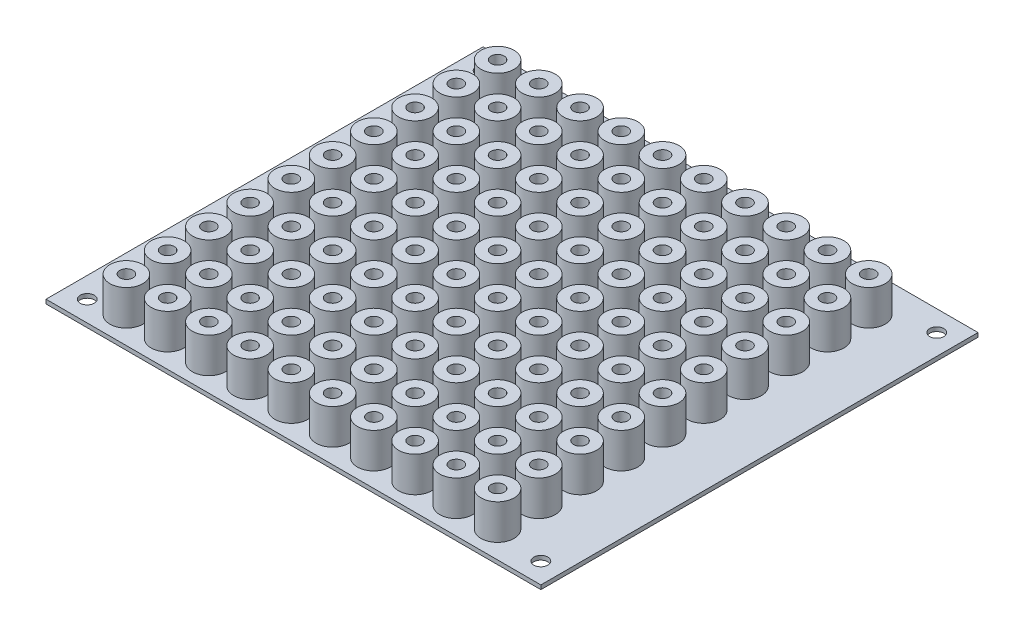
from build123d import *

# Parameters (mm, degrees)
SKETCH1_W           = 120
SKETCH1_H           = 106
SKETCH1_R           = 1.25
SKETCH1_R_2         = 1.7
BOSS_EXTRUDE1_DEPTH = 1
SKETCH2_R           = 4
SKETCH2_R_2         = 1.6
BOSS_EXTRUDE2_DEPTH = 8.525


with BuildPart() as part:
    # Sketch1 → Boss-Extrude1 (new body)
    with BuildSketch(Plane(origin=(0, 0, 0), x_dir=(1, 0, 0), z_dir=(0, 1, 0))):
        with Locations((60, 53)):
            Rectangle(SKETCH1_W, SKETCH1_H)
        with Locations((13, 66.5)):
            Circle(SKETCH1_R, mode=Mode.SUBTRACT)
        with Locations((23, 66.5)):
            Circle(SKETCH1_R, mode=Mode.SUBTRACT)
        with Locations((13, 96.5)):
            Circle(SKETCH1_R, mode=Mode.SUBTRACT)
        with Locations((5, 5)):
            Circle(SKETCH1_R_2, mode=Mode.SUBTRACT)
        with Locations((5, 101)):
            Circle(SKETCH1_R_2, mode=Mode.SUBTRACT)
        with Locations((115, 101)):
            Circle(SKETCH1_R_2, mode=Mode.SUBTRACT)
        with Locations((115, 5)):
            Circle(SKETCH1_R_2, mode=Mode.SUBTRACT)
        with Locations((23, 96.5)):
            Circle(SKETCH1_R, mode=Mode.SUBTRACT)
        with Locations((33, 96.5)):
            Circle(SKETCH1_R, mode=Mode.SUBTRACT)
        with Locations((23, 86.5)):
            Circle(SKETCH1_R, mode=Mode.SUBTRACT)
        with Locations((33, 86.5)):
            Circle(SKETCH1_R, mode=Mode.SUBTRACT)
        with Locations((23, 76.5)):
            Circle(SKETCH1_R, mode=Mode.SUBTRACT)
        with Locations((33, 76.5)):
            Circle(SKETCH1_R, mode=Mode.SUBTRACT)
        with Locations((13, 86.5)):
            Circle(SKETCH1_R, mode=Mode.SUBTRACT)
        with Locations((13, 76.5)):
            Circle(SKETCH1_R, mode=Mode.SUBTRACT)
        with Locations((33, 66.5)):
            Circle(SKETCH1_R, mode=Mode.SUBTRACT)
        with Locations((13, 56.5)):
            Circle(SKETCH1_R, mode=Mode.SUBTRACT)
        with Locations((23, 56.5)):
            Circle(SKETCH1_R, mode=Mode.SUBTRACT)
        with Locations((33, 56.5)):
            Circle(SKETCH1_R, mode=Mode.SUBTRACT)
        with Locations((13, 46.5)):
            Circle(SKETCH1_R, mode=Mode.SUBTRACT)
        with Locations((23, 46.5)):
            Circle(SKETCH1_R, mode=Mode.SUBTRACT)
        with Locations((33, 46.5)):
            Circle(SKETCH1_R, mode=Mode.SUBTRACT)
        with Locations((13, 36.5)):
            Circle(SKETCH1_R, mode=Mode.SUBTRACT)
        with Locations((23, 36.5)):
            Circle(SKETCH1_R, mode=Mode.SUBTRACT)
        with Locations((33, 36.5)):
            Circle(SKETCH1_R, mode=Mode.SUBTRACT)
        with Locations((13, 26.5)):
            Circle(SKETCH1_R, mode=Mode.SUBTRACT)
        with Locations((23, 26.5)):
            Circle(SKETCH1_R, mode=Mode.SUBTRACT)
        with Locations((33, 26.5)):
            Circle(SKETCH1_R, mode=Mode.SUBTRACT)
        with Locations((13, 16.5)):
            Circle(SKETCH1_R, mode=Mode.SUBTRACT)
        with Locations((23, 16.5)):
            Circle(SKETCH1_R, mode=Mode.SUBTRACT)
        with Locations((33, 16.5)):
            Circle(SKETCH1_R, mode=Mode.SUBTRACT)
        with Locations((13, 6.5)):
            Circle(SKETCH1_R, mode=Mode.SUBTRACT)
        with Locations((23, 6.5)):
            Circle(SKETCH1_R, mode=Mode.SUBTRACT)
        with Locations((33, 6.5)):
            Circle(SKETCH1_R, mode=Mode.SUBTRACT)
        with Locations((43, 96.5)):
            Circle(SKETCH1_R, mode=Mode.SUBTRACT)
        with Locations((53, 96.5)):
            Circle(SKETCH1_R, mode=Mode.SUBTRACT)
        with Locations((63, 96.5)):
            Circle(SKETCH1_R, mode=Mode.SUBTRACT)
        with Locations((73, 96.5)):
            Circle(SKETCH1_R, mode=Mode.SUBTRACT)
        with Locations((83, 96.5)):
            Circle(SKETCH1_R, mode=Mode.SUBTRACT)
        with Locations((93, 96.5)):
            Circle(SKETCH1_R, mode=Mode.SUBTRACT)
        with Locations((103, 96.5)):
            Circle(SKETCH1_R, mode=Mode.SUBTRACT)
        with Locations((43, 86.5)):
            Circle(SKETCH1_R, mode=Mode.SUBTRACT)
        with Locations((53, 86.5)):
            Circle(SKETCH1_R, mode=Mode.SUBTRACT)
        with Locations((63, 86.5)):
            Circle(SKETCH1_R, mode=Mode.SUBTRACT)
        with Locations((73, 86.5)):
            Circle(SKETCH1_R, mode=Mode.SUBTRACT)
        with Locations((83, 86.5)):
            Circle(SKETCH1_R, mode=Mode.SUBTRACT)
        with Locations((93, 86.5)):
            Circle(SKETCH1_R, mode=Mode.SUBTRACT)
        with Locations((103, 86.5)):
            Circle(SKETCH1_R, mode=Mode.SUBTRACT)
        with Locations((43, 76.5)):
            Circle(SKETCH1_R, mode=Mode.SUBTRACT)
        with Locations((53, 76.5)):
            Circle(SKETCH1_R, mode=Mode.SUBTRACT)
        with Locations((63, 76.5)):
            Circle(SKETCH1_R, mode=Mode.SUBTRACT)
        with Locations((73, 76.5)):
            Circle(SKETCH1_R, mode=Mode.SUBTRACT)
        with Locations((83, 76.5)):
            Circle(SKETCH1_R, mode=Mode.SUBTRACT)
        with Locations((93, 76.5)):
            Circle(SKETCH1_R, mode=Mode.SUBTRACT)
        with Locations((103, 76.5)):
            Circle(SKETCH1_R, mode=Mode.SUBTRACT)
        with Locations((43, 66.5)):
            Circle(SKETCH1_R, mode=Mode.SUBTRACT)
        with Locations((53, 66.5)):
            Circle(SKETCH1_R, mode=Mode.SUBTRACT)
        with Locations((63, 66.5)):
            Circle(SKETCH1_R, mode=Mode.SUBTRACT)
        with Locations((73, 66.5)):
            Circle(SKETCH1_R, mode=Mode.SUBTRACT)
        with Locations((83, 66.5)):
            Circle(SKETCH1_R, mode=Mode.SUBTRACT)
        with Locations((93, 66.5)):
            Circle(SKETCH1_R, mode=Mode.SUBTRACT)
        with Locations((103, 66.5)):
            Circle(SKETCH1_R, mode=Mode.SUBTRACT)
        with Locations((43, 56.5)):
            Circle(SKETCH1_R, mode=Mode.SUBTRACT)
        with Locations((53, 56.5)):
            Circle(SKETCH1_R, mode=Mode.SUBTRACT)
        with Locations((63, 56.5)):
            Circle(SKETCH1_R, mode=Mode.SUBTRACT)
        with Locations((73, 56.5)):
            Circle(SKETCH1_R, mode=Mode.SUBTRACT)
        with Locations((83, 56.5)):
            Circle(SKETCH1_R, mode=Mode.SUBTRACT)
        with Locations((93, 56.5)):
            Circle(SKETCH1_R, mode=Mode.SUBTRACT)
        with Locations((103, 56.5)):
            Circle(SKETCH1_R, mode=Mode.SUBTRACT)
        with Locations((43, 46.5)):
            Circle(SKETCH1_R, mode=Mode.SUBTRACT)
        with Locations((53, 46.5)):
            Circle(SKETCH1_R, mode=Mode.SUBTRACT)
        with Locations((63, 46.5)):
            Circle(SKETCH1_R, mode=Mode.SUBTRACT)
        with Locations((73, 46.5)):
            Circle(SKETCH1_R, mode=Mode.SUBTRACT)
        with Locations((83, 46.5)):
            Circle(SKETCH1_R, mode=Mode.SUBTRACT)
        with Locations((93, 46.5)):
            Circle(SKETCH1_R, mode=Mode.SUBTRACT)
        with Locations((103, 46.5)):
            Circle(SKETCH1_R, mode=Mode.SUBTRACT)
        with Locations((43, 36.5)):
            Circle(SKETCH1_R, mode=Mode.SUBTRACT)
        with Locations((53, 36.5)):
            Circle(SKETCH1_R, mode=Mode.SUBTRACT)
        with Locations((63, 36.5)):
            Circle(SKETCH1_R, mode=Mode.SUBTRACT)
        with Locations((73, 36.5)):
            Circle(SKETCH1_R, mode=Mode.SUBTRACT)
        with Locations((83, 36.5)):
            Circle(SKETCH1_R, mode=Mode.SUBTRACT)
        with Locations((93, 36.5)):
            Circle(SKETCH1_R, mode=Mode.SUBTRACT)
        with Locations((103, 36.5)):
            Circle(SKETCH1_R, mode=Mode.SUBTRACT)
        with Locations((43, 26.5)):
            Circle(SKETCH1_R, mode=Mode.SUBTRACT)
        with Locations((53, 26.5)):
            Circle(SKETCH1_R, mode=Mode.SUBTRACT)
        with Locations((63, 26.5)):
            Circle(SKETCH1_R, mode=Mode.SUBTRACT)
        with Locations((73, 26.5)):
            Circle(SKETCH1_R, mode=Mode.SUBTRACT)
        with Locations((83, 26.5)):
            Circle(SKETCH1_R, mode=Mode.SUBTRACT)
        with Locations((93, 26.5)):
            Circle(SKETCH1_R, mode=Mode.SUBTRACT)
        with Locations((103, 26.5)):
            Circle(SKETCH1_R, mode=Mode.SUBTRACT)
        with Locations((43, 16.5)):
            Circle(SKETCH1_R, mode=Mode.SUBTRACT)
        with Locations((53, 16.5)):
            Circle(SKETCH1_R, mode=Mode.SUBTRACT)
        with Locations((63, 16.5)):
            Circle(SKETCH1_R, mode=Mode.SUBTRACT)
        with Locations((73, 16.5)):
            Circle(SKETCH1_R, mode=Mode.SUBTRACT)
        with Locations((83, 16.5)):
            Circle(SKETCH1_R, mode=Mode.SUBTRACT)
        with Locations((93, 16.5)):
            Circle(SKETCH1_R, mode=Mode.SUBTRACT)
        with Locations((103, 16.5)):
            Circle(SKETCH1_R, mode=Mode.SUBTRACT)
        with Locations((43, 6.5)):
            Circle(SKETCH1_R, mode=Mode.SUBTRACT)
        with Locations((53, 6.5)):
            Circle(SKETCH1_R, mode=Mode.SUBTRACT)
        with Locations((63, 6.5)):
            Circle(SKETCH1_R, mode=Mode.SUBTRACT)
        with Locations((73, 6.5)):
            Circle(SKETCH1_R, mode=Mode.SUBTRACT)
        with Locations((83, 6.5)):
            Circle(SKETCH1_R, mode=Mode.SUBTRACT)
        with Locations((93, 6.5)):
            Circle(SKETCH1_R, mode=Mode.SUBTRACT)
        with Locations((103, 6.5)):
            Circle(SKETCH1_R, mode=Mode.SUBTRACT)
    extrude(amount=BOSS_EXTRUDE1_DEPTH)

    # Sketch2 → Boss-Extrude2 (add)
    with BuildSketch(Plane(origin=(0, 1, 0), x_dir=(1, 0, 0), z_dir=(0, 1, 0))):
        with Locations((13, 96.5)):
            Circle(SKETCH2_R)
        with Locations((13, 96.5)):
            Circle(SKETCH2_R_2, mode=Mode.SUBTRACT)
        with Locations((23, 96.5)):
            Circle(SKETCH2_R)
        with Locations((23, 96.5)):
            Circle(SKETCH2_R_2, mode=Mode.SUBTRACT)
        with Locations((33, 96.5)):
            Circle(SKETCH2_R)
        with Locations((33, 96.5)):
            Circle(SKETCH2_R_2, mode=Mode.SUBTRACT)
        with Locations((23, 86.5)):
            Circle(SKETCH2_R)
        with Locations((23, 86.5)):
            Circle(SKETCH2_R_2, mode=Mode.SUBTRACT)
        with Locations((33, 86.5)):
            Circle(SKETCH2_R)
        with Locations((33, 86.5)):
            Circle(SKETCH2_R_2, mode=Mode.SUBTRACT)
        with Locations((23, 76.5)):
            Circle(SKETCH2_R)
        with Locations((23, 76.5)):
            Circle(SKETCH2_R_2, mode=Mode.SUBTRACT)
        with Locations((33, 76.5)):
            Circle(SKETCH2_R)
        with Locations((33, 76.5)):
            Circle(SKETCH2_R_2, mode=Mode.SUBTRACT)
        with Locations((13, 86.5)):
            Circle(SKETCH2_R)
        with Locations((13, 86.5)):
            Circle(SKETCH2_R_2, mode=Mode.SUBTRACT)
        with Locations((13, 76.5)):
            Circle(SKETCH2_R)
        with Locations((13, 76.5)):
            Circle(SKETCH2_R_2, mode=Mode.SUBTRACT)
        with Locations((13, 66.5)):
            Circle(SKETCH2_R)
        with Locations((13, 66.5)):
            Circle(SKETCH2_R_2, mode=Mode.SUBTRACT)
        with Locations((23, 66.5)):
            Circle(SKETCH2_R)
        with Locations((23, 66.5)):
            Circle(SKETCH2_R_2, mode=Mode.SUBTRACT)
        with Locations((33, 66.5)):
            Circle(SKETCH2_R)
        with Locations((33, 66.5)):
            Circle(SKETCH2_R_2, mode=Mode.SUBTRACT)
        with Locations((13, 56.5)):
            Circle(SKETCH2_R)
        with Locations((13, 56.5)):
            Circle(SKETCH2_R_2, mode=Mode.SUBTRACT)
        with Locations((23, 56.5)):
            Circle(SKETCH2_R)
        with Locations((23, 56.5)):
            Circle(SKETCH2_R_2, mode=Mode.SUBTRACT)
        with Locations((33, 56.5)):
            Circle(SKETCH2_R)
        with Locations((33, 56.5)):
            Circle(SKETCH2_R_2, mode=Mode.SUBTRACT)
        with Locations((13, 46.5)):
            Circle(SKETCH2_R)
        with Locations((13, 46.5)):
            Circle(SKETCH2_R_2, mode=Mode.SUBTRACT)
        with Locations((23, 46.5)):
            Circle(SKETCH2_R)
        with Locations((23, 46.5)):
            Circle(SKETCH2_R_2, mode=Mode.SUBTRACT)
        with Locations((33, 46.5)):
            Circle(SKETCH2_R)
        with Locations((33, 46.5)):
            Circle(SKETCH2_R_2, mode=Mode.SUBTRACT)
        with Locations((13, 36.5)):
            Circle(SKETCH2_R)
        with Locations((13, 36.5)):
            Circle(SKETCH2_R_2, mode=Mode.SUBTRACT)
        with Locations((23, 36.5)):
            Circle(SKETCH2_R)
        with Locations((23, 36.5)):
            Circle(SKETCH2_R_2, mode=Mode.SUBTRACT)
        with Locations((33, 36.5)):
            Circle(SKETCH2_R)
        with Locations((33, 36.5)):
            Circle(SKETCH2_R_2, mode=Mode.SUBTRACT)
        with Locations((13, 26.5)):
            Circle(SKETCH2_R)
        with Locations((13, 26.5)):
            Circle(SKETCH2_R_2, mode=Mode.SUBTRACT)
        with Locations((23, 26.5)):
            Circle(SKETCH2_R)
        with Locations((23, 26.5)):
            Circle(SKETCH2_R_2, mode=Mode.SUBTRACT)
        with Locations((33, 26.5)):
            Circle(SKETCH2_R)
        with Locations((33, 26.5)):
            Circle(SKETCH2_R_2, mode=Mode.SUBTRACT)
        with Locations((13, 16.5)):
            Circle(SKETCH2_R)
        with Locations((13, 16.5)):
            Circle(SKETCH2_R_2, mode=Mode.SUBTRACT)
        with Locations((23, 16.5)):
            Circle(SKETCH2_R)
        with Locations((23, 16.5)):
            Circle(SKETCH2_R_2, mode=Mode.SUBTRACT)
        with Locations((33, 16.5)):
            Circle(SKETCH2_R)
        with Locations((33, 16.5)):
            Circle(SKETCH2_R_2, mode=Mode.SUBTRACT)
        with Locations((13, 6.5)):
            Circle(SKETCH2_R)
        with Locations((13, 6.5)):
            Circle(SKETCH2_R_2, mode=Mode.SUBTRACT)
        with Locations((23, 6.5)):
            Circle(SKETCH2_R)
        with Locations((23, 6.5)):
            Circle(SKETCH2_R_2, mode=Mode.SUBTRACT)
        with Locations((33, 6.5)):
            Circle(SKETCH2_R)
        with Locations((33, 6.5)):
            Circle(SKETCH2_R_2, mode=Mode.SUBTRACT)
        with Locations((43, 96.5)):
            Circle(SKETCH2_R)
        with Locations((43, 96.5)):
            Circle(SKETCH2_R_2, mode=Mode.SUBTRACT)
        with Locations((53, 96.5)):
            Circle(SKETCH2_R)
        with Locations((53, 96.5)):
            Circle(SKETCH2_R_2, mode=Mode.SUBTRACT)
        with Locations((63, 96.5)):
            Circle(SKETCH2_R)
        with Locations((63, 96.5)):
            Circle(SKETCH2_R_2, mode=Mode.SUBTRACT)
        with Locations((73, 96.5)):
            Circle(SKETCH2_R)
        with Locations((73, 96.5)):
            Circle(SKETCH2_R_2, mode=Mode.SUBTRACT)
        with Locations((83, 96.5)):
            Circle(SKETCH2_R)
        with Locations((83, 96.5)):
            Circle(SKETCH2_R_2, mode=Mode.SUBTRACT)
        with Locations((93, 96.5)):
            Circle(SKETCH2_R)
        with Locations((93, 96.5)):
            Circle(SKETCH2_R_2, mode=Mode.SUBTRACT)
        with Locations((103, 96.5)):
            Circle(SKETCH2_R)
        with Locations((103, 96.5)):
            Circle(SKETCH2_R_2, mode=Mode.SUBTRACT)
        with Locations((43, 86.5)):
            Circle(SKETCH2_R)
        with Locations((43, 86.5)):
            Circle(SKETCH2_R_2, mode=Mode.SUBTRACT)
        with Locations((53, 86.5)):
            Circle(SKETCH2_R)
        with Locations((53, 86.5)):
            Circle(SKETCH2_R_2, mode=Mode.SUBTRACT)
        with Locations((63, 86.5)):
            Circle(SKETCH2_R)
        with Locations((63, 86.5)):
            Circle(SKETCH2_R_2, mode=Mode.SUBTRACT)
        with Locations((73, 86.5)):
            Circle(SKETCH2_R)
        with Locations((73, 86.5)):
            Circle(SKETCH2_R_2, mode=Mode.SUBTRACT)
        with Locations((83, 86.5)):
            Circle(SKETCH2_R)
        with Locations((83, 86.5)):
            Circle(SKETCH2_R_2, mode=Mode.SUBTRACT)
        with Locations((93, 86.5)):
            Circle(SKETCH2_R)
        with Locations((93, 86.5)):
            Circle(SKETCH2_R_2, mode=Mode.SUBTRACT)
        with Locations((103, 86.5)):
            Circle(SKETCH2_R)
        with Locations((103, 86.5)):
            Circle(SKETCH2_R_2, mode=Mode.SUBTRACT)
        with Locations((43, 76.5)):
            Circle(SKETCH2_R)
        with Locations((43, 76.5)):
            Circle(SKETCH2_R_2, mode=Mode.SUBTRACT)
        with Locations((53, 76.5)):
            Circle(SKETCH2_R)
        with Locations((53, 76.5)):
            Circle(SKETCH2_R_2, mode=Mode.SUBTRACT)
        with Locations((63, 76.5)):
            Circle(SKETCH2_R)
        with Locations((63, 76.5)):
            Circle(SKETCH2_R_2, mode=Mode.SUBTRACT)
        with Locations((73, 76.5)):
            Circle(SKETCH2_R)
        with Locations((73, 76.5)):
            Circle(SKETCH2_R_2, mode=Mode.SUBTRACT)
        with Locations((83, 76.5)):
            Circle(SKETCH2_R)
        with Locations((83, 76.5)):
            Circle(SKETCH2_R_2, mode=Mode.SUBTRACT)
        with Locations((93, 76.5)):
            Circle(SKETCH2_R)
        with Locations((93, 76.5)):
            Circle(SKETCH2_R_2, mode=Mode.SUBTRACT)
        with Locations((103, 76.5)):
            Circle(SKETCH2_R)
        with Locations((103, 76.5)):
            Circle(SKETCH2_R_2, mode=Mode.SUBTRACT)
        with Locations((43, 66.5)):
            Circle(SKETCH2_R)
        with Locations((43, 66.5)):
            Circle(SKETCH2_R_2, mode=Mode.SUBTRACT)
        with Locations((53, 66.5)):
            Circle(SKETCH2_R)
        with Locations((53, 66.5)):
            Circle(SKETCH2_R_2, mode=Mode.SUBTRACT)
        with Locations((63, 66.5)):
            Circle(SKETCH2_R)
        with Locations((63, 66.5)):
            Circle(SKETCH2_R_2, mode=Mode.SUBTRACT)
        with Locations((73, 66.5)):
            Circle(SKETCH2_R)
        with Locations((73, 66.5)):
            Circle(SKETCH2_R_2, mode=Mode.SUBTRACT)
        with Locations((83, 66.5)):
            Circle(SKETCH2_R)
        with Locations((83, 66.5)):
            Circle(SKETCH2_R_2, mode=Mode.SUBTRACT)
        with Locations((93, 66.5)):
            Circle(SKETCH2_R)
        with Locations((93, 66.5)):
            Circle(SKETCH2_R_2, mode=Mode.SUBTRACT)
        with Locations((103, 66.5)):
            Circle(SKETCH2_R)
        with Locations((103, 66.5)):
            Circle(SKETCH2_R_2, mode=Mode.SUBTRACT)
        with Locations((43, 56.5)):
            Circle(SKETCH2_R)
        with Locations((43, 56.5)):
            Circle(SKETCH2_R_2, mode=Mode.SUBTRACT)
        with Locations((53, 56.5)):
            Circle(SKETCH2_R)
        with Locations((53, 56.5)):
            Circle(SKETCH2_R_2, mode=Mode.SUBTRACT)
        with Locations((63, 56.5)):
            Circle(SKETCH2_R)
        with Locations((63, 56.5)):
            Circle(SKETCH2_R_2, mode=Mode.SUBTRACT)
        with Locations((73, 56.5)):
            Circle(SKETCH2_R)
        with Locations((73, 56.5)):
            Circle(SKETCH2_R_2, mode=Mode.SUBTRACT)
        with Locations((83, 56.5)):
            Circle(SKETCH2_R)
        with Locations((83, 56.5)):
            Circle(SKETCH2_R_2, mode=Mode.SUBTRACT)
        with Locations((93, 56.5)):
            Circle(SKETCH2_R)
        with Locations((93, 56.5)):
            Circle(SKETCH2_R_2, mode=Mode.SUBTRACT)
        with Locations((103, 56.5)):
            Circle(SKETCH2_R)
        with Locations((103, 56.5)):
            Circle(SKETCH2_R_2, mode=Mode.SUBTRACT)
        with Locations((43, 46.5)):
            Circle(SKETCH2_R)
        with Locations((43, 46.5)):
            Circle(SKETCH2_R_2, mode=Mode.SUBTRACT)
        with Locations((53, 46.5)):
            Circle(SKETCH2_R)
        with Locations((53, 46.5)):
            Circle(SKETCH2_R_2, mode=Mode.SUBTRACT)
        with Locations((63, 46.5)):
            Circle(SKETCH2_R)
        with Locations((63, 46.5)):
            Circle(SKETCH2_R_2, mode=Mode.SUBTRACT)
        with Locations((73, 46.5)):
            Circle(SKETCH2_R)
        with Locations((73, 46.5)):
            Circle(SKETCH2_R_2, mode=Mode.SUBTRACT)
        with Locations((83, 46.5)):
            Circle(SKETCH2_R)
        with Locations((83, 46.5)):
            Circle(SKETCH2_R_2, mode=Mode.SUBTRACT)
        with Locations((93, 46.5)):
            Circle(SKETCH2_R)
        with Locations((93, 46.5)):
            Circle(SKETCH2_R_2, mode=Mode.SUBTRACT)
        with Locations((103, 46.5)):
            Circle(SKETCH2_R)
        with Locations((103, 46.5)):
            Circle(SKETCH2_R_2, mode=Mode.SUBTRACT)
        with Locations((43, 36.5)):
            Circle(SKETCH2_R)
        with Locations((43, 36.5)):
            Circle(SKETCH2_R_2, mode=Mode.SUBTRACT)
        with Locations((53, 36.5)):
            Circle(SKETCH2_R)
        with Locations((53, 36.5)):
            Circle(SKETCH2_R_2, mode=Mode.SUBTRACT)
        with Locations((63, 36.5)):
            Circle(SKETCH2_R)
        with Locations((63, 36.5)):
            Circle(SKETCH2_R_2, mode=Mode.SUBTRACT)
        with Locations((73, 36.5)):
            Circle(SKETCH2_R)
        with Locations((73, 36.5)):
            Circle(SKETCH2_R_2, mode=Mode.SUBTRACT)
        with Locations((83, 36.5)):
            Circle(SKETCH2_R)
        with Locations((83, 36.5)):
            Circle(SKETCH2_R_2, mode=Mode.SUBTRACT)
        with Locations((93, 36.5)):
            Circle(SKETCH2_R)
        with Locations((93, 36.5)):
            Circle(SKETCH2_R_2, mode=Mode.SUBTRACT)
        with Locations((103, 36.5)):
            Circle(SKETCH2_R)
        with Locations((103, 36.5)):
            Circle(SKETCH2_R_2, mode=Mode.SUBTRACT)
        with Locations((43, 26.5)):
            Circle(SKETCH2_R)
        with Locations((43, 26.5)):
            Circle(SKETCH2_R_2, mode=Mode.SUBTRACT)
        with Locations((53, 26.5)):
            Circle(SKETCH2_R)
        with Locations((53, 26.5)):
            Circle(SKETCH2_R_2, mode=Mode.SUBTRACT)
        with Locations((63, 26.5)):
            Circle(SKETCH2_R)
        with Locations((63, 26.5)):
            Circle(SKETCH2_R_2, mode=Mode.SUBTRACT)
        with Locations((73, 26.5)):
            Circle(SKETCH2_R)
        with Locations((73, 26.5)):
            Circle(SKETCH2_R_2, mode=Mode.SUBTRACT)
        with Locations((83, 26.5)):
            Circle(SKETCH2_R)
        with Locations((83, 26.5)):
            Circle(SKETCH2_R_2, mode=Mode.SUBTRACT)
        with Locations((93, 26.5)):
            Circle(SKETCH2_R)
        with Locations((93, 26.5)):
            Circle(SKETCH2_R_2, mode=Mode.SUBTRACT)
        with Locations((103, 26.5)):
            Circle(SKETCH2_R)
        with Locations((103, 26.5)):
            Circle(SKETCH2_R_2, mode=Mode.SUBTRACT)
        with Locations((43, 16.5)):
            Circle(SKETCH2_R)
        with Locations((43, 16.5)):
            Circle(SKETCH2_R_2, mode=Mode.SUBTRACT)
        with Locations((53, 16.5)):
            Circle(SKETCH2_R)
        with Locations((53, 16.5)):
            Circle(SKETCH2_R_2, mode=Mode.SUBTRACT)
        with Locations((63, 16.5)):
            Circle(SKETCH2_R)
        with Locations((63, 16.5)):
            Circle(SKETCH2_R_2, mode=Mode.SUBTRACT)
        with Locations((73, 16.5)):
            Circle(SKETCH2_R)
        with Locations((73, 16.5)):
            Circle(SKETCH2_R_2, mode=Mode.SUBTRACT)
        with Locations((83, 16.5)):
            Circle(SKETCH2_R)
        with Locations((83, 16.5)):
            Circle(SKETCH2_R_2, mode=Mode.SUBTRACT)
        with Locations((93, 16.5)):
            Circle(SKETCH2_R)
        with Locations((93, 16.5)):
            Circle(SKETCH2_R_2, mode=Mode.SUBTRACT)
        with Locations((103, 16.5)):
            Circle(SKETCH2_R)
        with Locations((103, 16.5)):
            Circle(SKETCH2_R_2, mode=Mode.SUBTRACT)
        with Locations((43, 6.5)):
            Circle(SKETCH2_R)
        with Locations((43, 6.5)):
            Circle(SKETCH2_R_2, mode=Mode.SUBTRACT)
        with Locations((53, 6.5)):
            Circle(SKETCH2_R)
        with Locations((53, 6.5)):
            Circle(SKETCH2_R_2, mode=Mode.SUBTRACT)
        with Locations((63, 6.5)):
            Circle(SKETCH2_R)
        with Locations((63, 6.5)):
            Circle(SKETCH2_R_2, mode=Mode.SUBTRACT)
        with Locations((73, 6.5)):
            Circle(SKETCH2_R)
        with Locations((73, 6.5)):
            Circle(SKETCH2_R_2, mode=Mode.SUBTRACT)
        with Locations((83, 6.5)):
            Circle(SKETCH2_R)
        with Locations((83, 6.5)):
            Circle(SKETCH2_R_2, mode=Mode.SUBTRACT)
        with Locations((93, 6.5)):
            Circle(SKETCH2_R)
        with Locations((93, 6.5)):
            Circle(SKETCH2_R_2, mode=Mode.SUBTRACT)
        with Locations((103, 6.5)):
            Circle(SKETCH2_R)
        with Locations((103, 6.5)):
            Circle(SKETCH2_R_2, mode=Mode.SUBTRACT)
    extrude(amount=BOSS_EXTRUDE2_DEPTH)


solid = part.part
